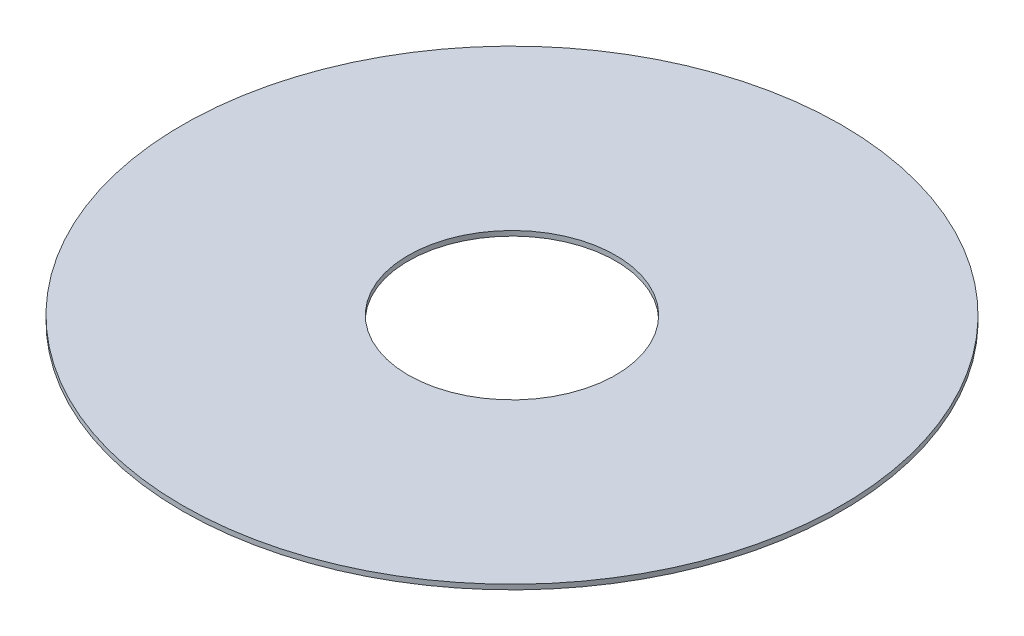
from build123d import *

# Parameters (mm, degrees)
SKETCH1_R           = 34.29
SKETCH1_R_2         = 10.795
BOSS_EXTRUDE1_DEPTH = 0.508


with BuildPart() as part:
    # Sketch1 → Boss-Extrude1 (new body)
    with BuildSketch(Plane(origin=(0, 0, 0), x_dir=(1, 0, 0), z_dir=(0, 1, 0))):
        Circle(SKETCH1_R)
        Circle(SKETCH1_R_2, mode=Mode.SUBTRACT)
    extrude(amount=BOSS_EXTRUDE1_DEPTH)


solid = part.part
